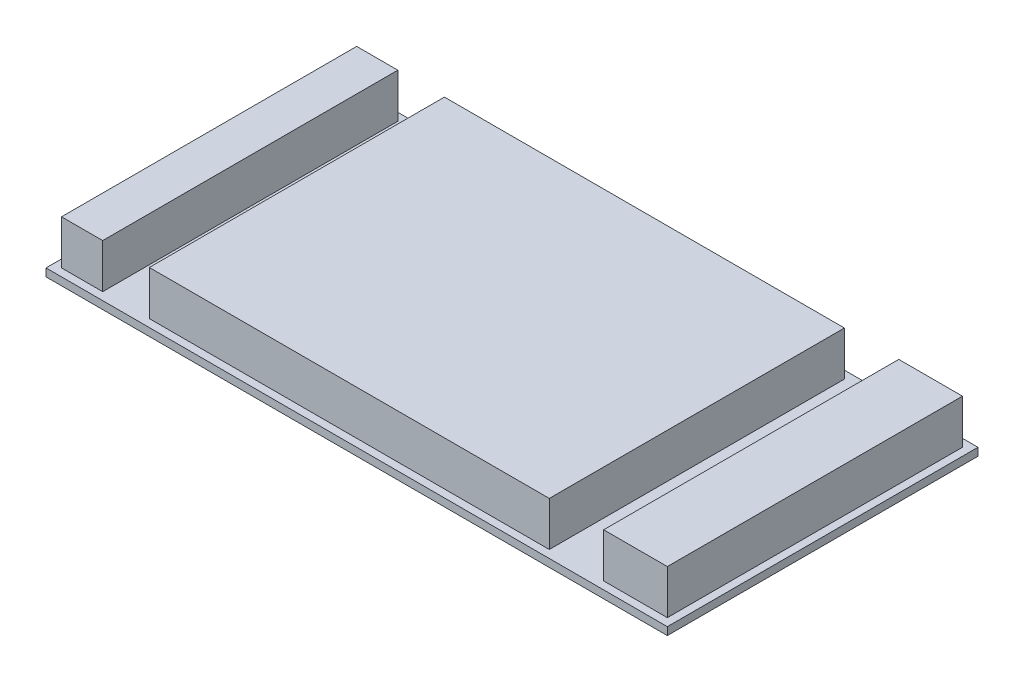
from build123d import *

# Parameters (mm, degrees)
SKETCH1_W           = 203.2
SKETCH1_H           = 101.6
BOSS_EXTRUDE1_DEPTH = 2.54
SKETCH2_W           = 198.12
SKETCH2_H           = 96.52
BOSS_EXTRUDE2_DEPTH = 14.478
SKETCH4_W           = 17.78
SKETCH4_H           = 14.478
SKETCH4_W_2         = 15.24
CUT_EXTRUDE6_DEPTH  = 101.6


with BuildPart() as part:
    # Sketch1 → Boss-Extrude1 (new body)
    with BuildSketch(Plane(origin=(0, 0, 0), x_dir=(1, 0, 0), z_dir=(0, 1, 0))):
        with Locations((-18.181052632, -25.132631579)):
            Rectangle(SKETCH1_W, SKETCH1_H)
    extrude(amount=BOSS_EXTRUDE1_DEPTH)

    # Sketch2 → Boss-Extrude2 (add)
    with BuildSketch(Plane(origin=(0, 2.54, 0), x_dir=(1, 0, 0), z_dir=(0, 1, 0))):
        with Locations((-18.181052632, -25.132631579)):
            Rectangle(SKETCH2_W, SKETCH2_H)
    extrude(amount=BOSS_EXTRUDE2_DEPTH)

    # Sketch4 → Cut-Extrude6 (cut)
    with BuildSketch(Plane(origin=(0, 0, -23.127368421), x_dir=(-1, 0, 0), z_dir=(0, 0, -1))):
        with Locations((-51.160947368, 9.779)):
            Rectangle(SKETCH4_W, SKETCH4_H)
        with Locations((96.159052632, 9.779)):
            Rectangle(SKETCH4_W_2, SKETCH4_H)
    extrude(amount=-CUT_EXTRUDE6_DEPTH, mode=Mode.SUBTRACT)


solid = part.part
